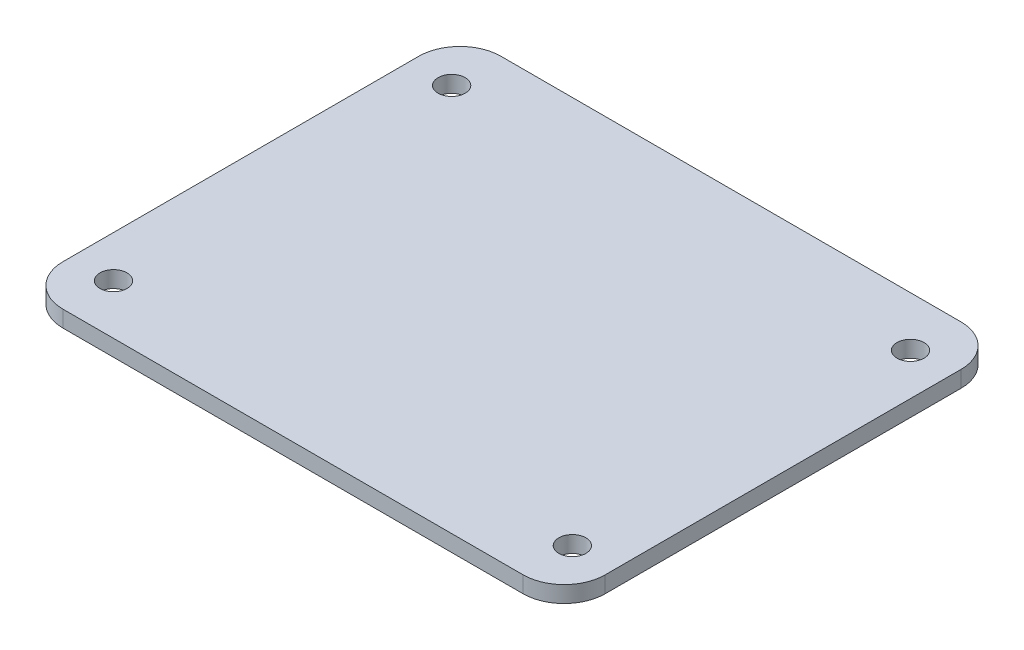
from build123d import *

# Parameters (mm, degrees)
ESQUISSE1_W        = 66.04
ESQUISSE1_H        = 53.34
ESQUISSE1_R        = 1.65
BOSS_EXTRU_1_DEPTH = 2
CONG_1_R           = 5


with BuildPart() as part:
    # Esquisse1 → Boss.-Extru.1 (new body)
    with BuildSketch(Plane(origin=(0, 0, 0), x_dir=(1, 0, 0), z_dir=(0, 1, 0))):
        Rectangle(ESQUISSE1_W, ESQUISSE1_H)
        with Locations((-27.94, 20.59)):
            Circle(ESQUISSE1_R, mode=Mode.SUBTRACT)
        with Locations((27.94, 20.59)):
            Circle(ESQUISSE1_R, mode=Mode.SUBTRACT)
        with Locations((27.94, -20.59)):
            Circle(ESQUISSE1_R, mode=Mode.SUBTRACT)
        with Locations((-27.94, -20.59)):
            Circle(ESQUISSE1_R, mode=Mode.SUBTRACT)
    extrude(amount=BOSS_EXTRU_1_DEPTH)

    # Congé1
    cong_1_edges = [part.edges().sort_by_distance(p)[0] for p in [
        (33.02, 1, 26.67),
        (-33.02, 1, 26.67),
        (-33.02, 1, -26.67),
        (33.02, 1, -26.67),
    ]]
    fillet(cong_1_edges, radius=CONG_1_R)


solid = part.part
